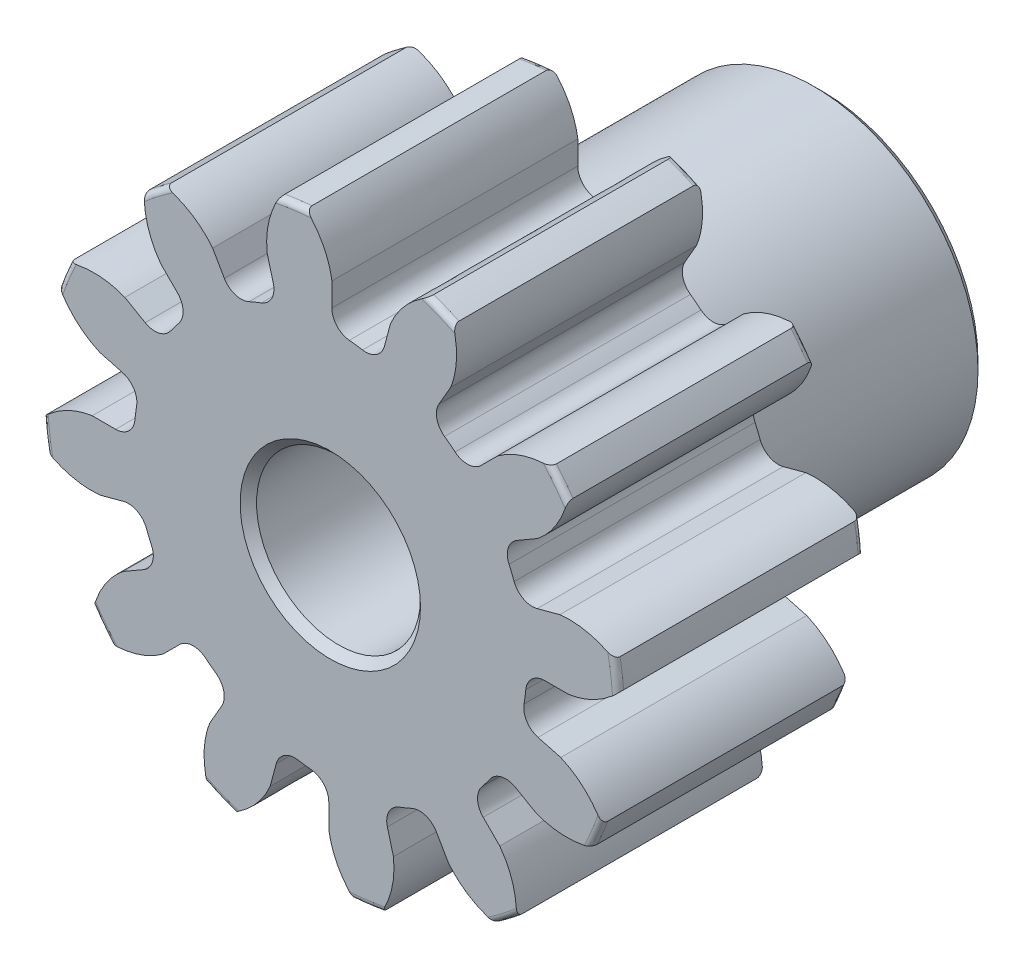
from build123d import *

# Parameters (mm, degrees)
SKETCH1_R                = 5.588
BOSS_EXTRUDE1_DEPTH      = 4.7625
SKETCH2_W                = 4.7625
SKETCH2_H                = 3.175
FILLET2_R                = 0.11176
CUT_EXTRUDE1_DEPTH       = 10.525
FILLET1_R                = 0.37404675
CIRPATTERN1_COUNT        = 12
FILLET1_OF_CIRPATTERN1_R = 0.37404675
SKETCH5_R                = 1.5875
CUT_EXTRUDE2_DEPTH       = 10.525
CHAMFER1_SIZE            = 0.15875


with BuildPart() as part:
    # Sketch1 → Boss-Extrude1 (new body)
    with BuildSketch(Plane.XY):
        Circle(SKETCH1_R)
    extrude(amount=-BOSS_EXTRUDE1_DEPTH)

    # Sketch2 → Revolve1 (revolve)
    with BuildSketch(Plane(origin=(0, 0, 0), x_dir=(0, 0, -1), z_dir=(1, 0, 0))):
        with Locations((7.14375, 1.5875)):
            Rectangle(SKETCH2_W, SKETCH2_H)
    revolve(axis=Axis((0, 0, -4.7625), (0, 0, -1)))

    # Fillet2
    fillet2_edges = [part.edges().sort_by_distance(p)[0] for p in [
        (-5.588, 0, 0),
        (-5.588, 0, -4.7625),
        (0, -3.175, -4.7625),
    ]]
    fillet(fillet2_edges, radius=FILLET2_R)

    # Sketch4 → Cut-Extrude1 (cut, through all)
    with BuildSketch(Plane.XY):
        with BuildLine():
            Line((0.029739909, 4.610707224), (0.029739909, 3.801946185))
            ThreePointArc((0.029739909, 3.801946185), (0.496269895, 3.769535176), (0.955291788, 3.68009468))
            Line((0.955291788, 3.68009468), (1.164615026, 4.461297727))
            add(Edge.make_bspline(
                [(1.916362889, 5.271603703), (1.385962247, 4.972426462), (1.164615026, 4.461297727)],
                knots=[0, 0, 0, 1, 1, 1], degree=2))
            ThreePointArc((1.916362889, 5.271603703), (0.73213907, 5.5611352), (-0.486669549, 5.587969674))
            add(Edge.make_bspline(
                [(-0.486669549, 5.587969674), (-0.051774899, 5.161708596), (0.029739909, 4.610707224)],
                knots=[0, 0, 0, 1, 1, 1], degree=2))
        make_face()
    cut_extrude1 = extrude(amount=-CUT_EXTRUDE1_DEPTH, mode=Mode.SUBTRACT)

    # Fillet1
    fillet1_edges = [part.edges().sort_by_distance(p)[0] for p in [
        (0.955291788, 3.68009468, -2.38125),
        (0.029739909, 3.801946185, -2.38125),
    ]]
    fillet(fillet1_edges, radius=FILLET1_R)

    # CirPattern1: Cut-Extrude1 ×12 about axis
    cirpattern1_axis = Axis((0, 0, -4.7625), (0, 0, 1))
    for i in range(1, CIRPATTERN1_COUNT):
        add(cut_extrude1.rotate(cirpattern1_axis, i * 360 / CIRPATTERN1_COUNT), mode=Mode.SUBTRACT)

    # Fillet1 of CirPattern1
    fillet1_of_cirpattern1_edges = [part.edges().sort_by_distance(p)[0] for p in [
        (-1.012740384, 3.664701375, -2.38125),
        (-1.875217576, 3.307451934, -2.38125),
        (-2.709409587, 2.667354296, -2.38125),
        (-3.277712025, 1.926728609, -2.38125),
        (-3.68009468, 0.955291788, -2.38125),
        (-3.801946185, 0.029739909, -2.38125),
        (-3.664701375, -1.012740384, -2.38125),
        (-3.307451934, -1.875217576, -2.38125),
        (-2.667354296, -2.709409587, -2.38125),
        (-1.926728609, -3.277712025, -2.38125),
        (-0.955291788, -3.68009468, -2.38125),
        (-0.029739909, -3.801946185, -2.38125),
        (1.012740384, -3.664701375, -2.38125),
        (1.875217576, -3.307451934, -2.38125),
        (2.709409587, -2.667354296, -2.38125),
        (3.277712025, -1.926728609, -2.38125),
        (3.68009468, -0.955291788, -2.38125),
        (3.801946185, -0.029739909, -2.38125),
        (3.664701375, 1.012740384, -2.38125),
        (3.307451934, 1.875217576, -2.38125),
        (2.667354296, 2.709409587, -2.38125),
        (1.926728609, 3.277712025, -2.38125),
    ]]
    fillet(fillet1_of_cirpattern1_edges, radius=FILLET1_OF_CIRPATTERN1_R)

    # Sketch5 → Cut-Extrude2 (cut, through all)
    with BuildSketch(Plane.XY):
        Circle(SKETCH5_R)
    extrude(amount=-CUT_EXTRUDE2_DEPTH, mode=Mode.SUBTRACT)

    # Chamfer1
    chamfer1_edges = [part.edges().sort_by_distance(p)[0] for p in [
        (0, -3.175, -9.525),
        (-1.5875, 0, -9.525),
        (-1.5875, 0, 0),
    ]]
    chamfer(chamfer1_edges, length=CHAMFER1_SIZE)


solid = part.part
